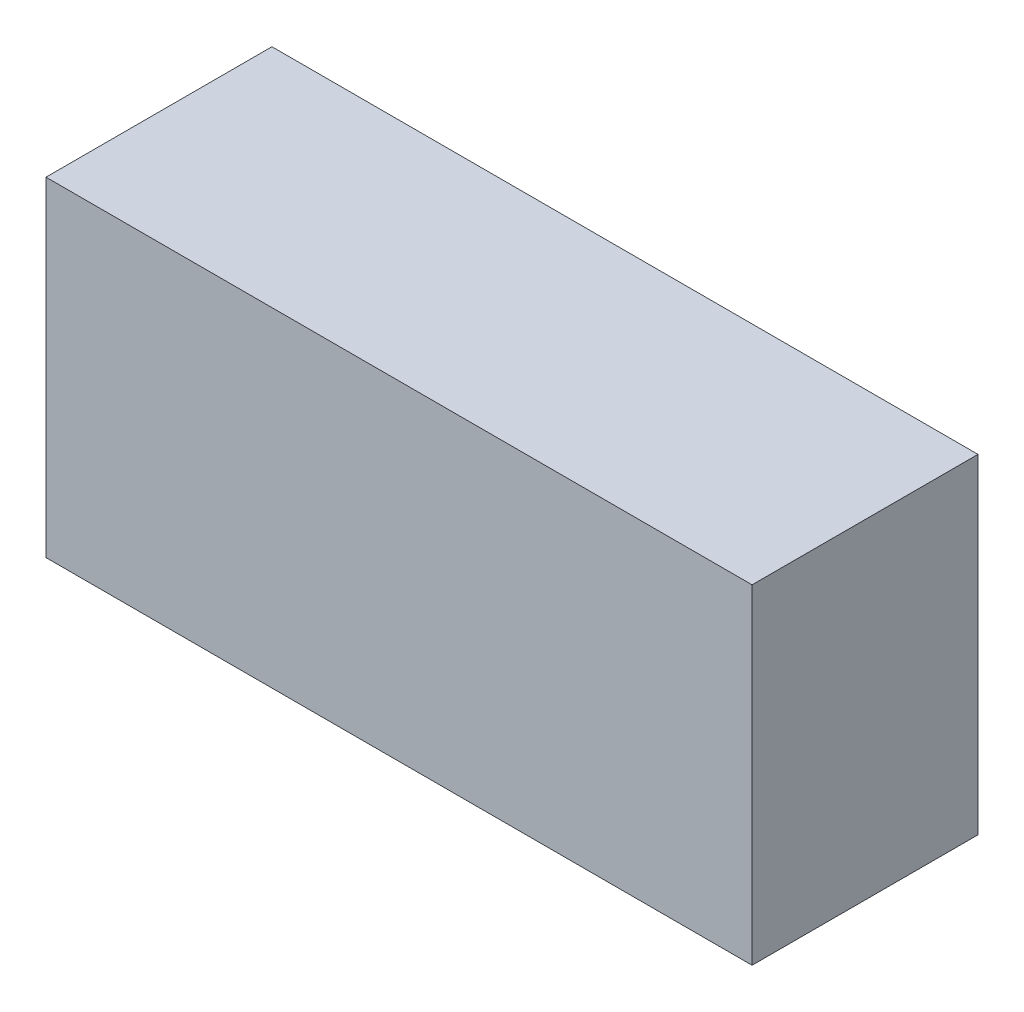
from build123d import *

# Parameters (mm, degrees)
SKETCH1_W           = 75
SKETCH1_H           = 35
BOSS_EXTRUDE1_DEPTH = 24


with BuildPart() as part:
    # Sketch1 → Boss-Extrude1 (new body)
    with BuildSketch(Plane.XY):
        with Locations((37.5, 17.5)):
            Rectangle(SKETCH1_W, SKETCH1_H)
    extrude(amount=BOSS_EXTRUDE1_DEPTH)


solid = part.part
